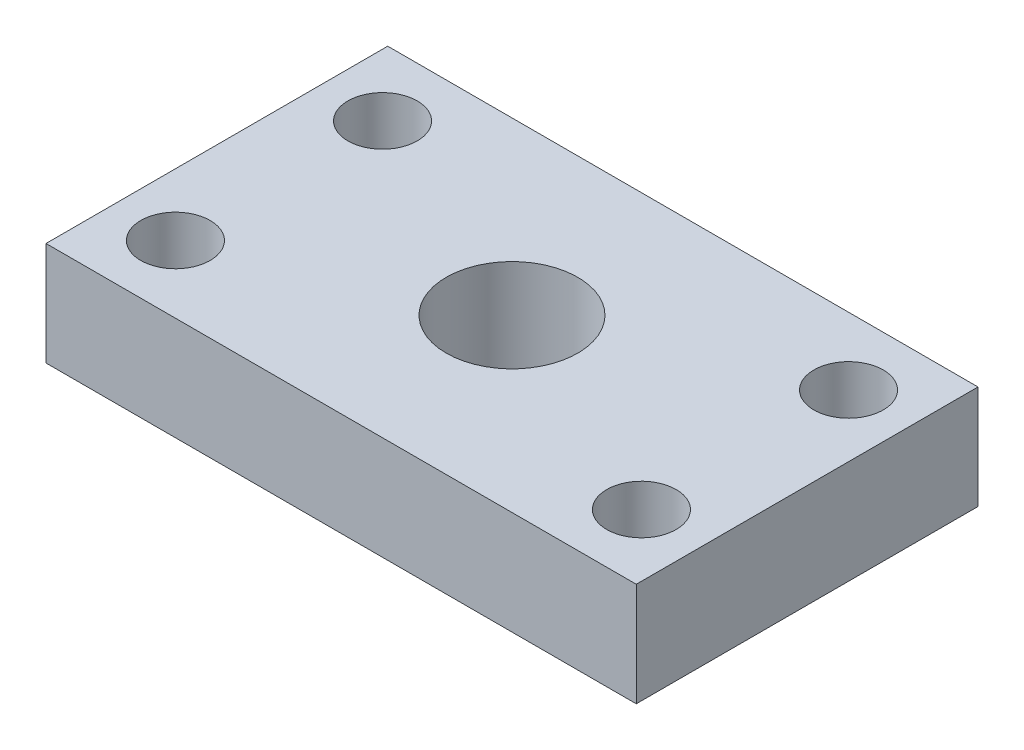
from build123d import *

# Parameters (mm, degrees)
SKETCH1_W                 = 57
SKETCH1_H                 = 33
BOSS_EXTRUDE1_DEPTH       = 10
SKETCH3_R                 = 3.35
CUT_EXTRUDE1_DEPTH        = 11
SKETCH4_R                 = 3.35
CUT_EXTRUDE2_DEPTH        = 11
SKETCH10_R                = 3.35
CUT_EXTRUDE5_DEPTH        = 11
SKETCH12_R                = 3.35
CUT_EXTRUDE6_DEPTH        = 11
F_8_32_TAPPED_HOLE1_D     = 3.4544
F_8_32_TAPPED_HOLE1_DEPTH = 5
F_8_32_TAPPED_HOLE1_TIP   = 1.037806461
F_0_535_40_TAPPED_HOLE1_D = 12.7


with BuildPart() as part:
    # Sketch1 → Boss-Extrude1 (new body)
    with BuildSketch(Plane(origin=(0, 0, 0), x_dir=(1, 0, 0), z_dir=(0, 1, 0))):
        with Locations((28.5, 16.5)):
            Rectangle(SKETCH1_W, SKETCH1_H)
    extrude(amount=BOSS_EXTRUDE1_DEPTH)

    # Sketch3 → Cut-Extrude1 (cut, through all)
    with BuildSketch(Plane.XZ):
        with Locations((6, -6.5)):
            Circle(SKETCH3_R)
    extrude(amount=-CUT_EXTRUDE1_DEPTH, mode=Mode.SUBTRACT)

    # Sketch4 → Cut-Extrude2 (cut, through all)
    with BuildSketch(Plane.XZ):
        with Locations((51, -26.5)):
            Circle(SKETCH4_R)
    extrude(amount=-CUT_EXTRUDE2_DEPTH, mode=Mode.SUBTRACT)

    # Sketch10 → Cut-Extrude5 (cut, through all)
    with BuildSketch(Plane.XZ):
        with Locations((6, -26.5)):
            Circle(SKETCH10_R)
    extrude(amount=-CUT_EXTRUDE5_DEPTH, mode=Mode.SUBTRACT)

    # Sketch12 → Cut-Extrude6 (cut, through all)
    with BuildSketch(Plane.XZ):
        with Locations((51, -6.5)):
            Circle(SKETCH12_R)
    extrude(amount=-CUT_EXTRUDE6_DEPTH, mode=Mode.SUBTRACT)

    # #8-32 Tapped Hole1
    with Locations(Plane(origin=(0, 0, -33), x_dir=(-1, 0, 0), z_dir=(0, 0, -1))):
        with Locations((-28.5, 5)):
            Hole(F_8_32_TAPPED_HOLE1_D / 2, depth=F_8_32_TAPPED_HOLE1_DEPTH)
            with Locations((0, 0, -(F_8_32_TAPPED_HOLE1_DEPTH + F_8_32_TAPPED_HOLE1_TIP / 2))):  # 118° drill point
                Cone(0, F_8_32_TAPPED_HOLE1_D / 2, F_8_32_TAPPED_HOLE1_TIP, mode=Mode.SUBTRACT)

    # 0.535-40 Tapped Hole1 (through all)
    with Locations(Plane(origin=(0, 10, 0), x_dir=(1, 0, 0), z_dir=(0, 1, 0))):
        with Locations((28.5, 16.5)):
            Hole(F_0_535_40_TAPPED_HOLE1_D / 2)


solid = part.part
